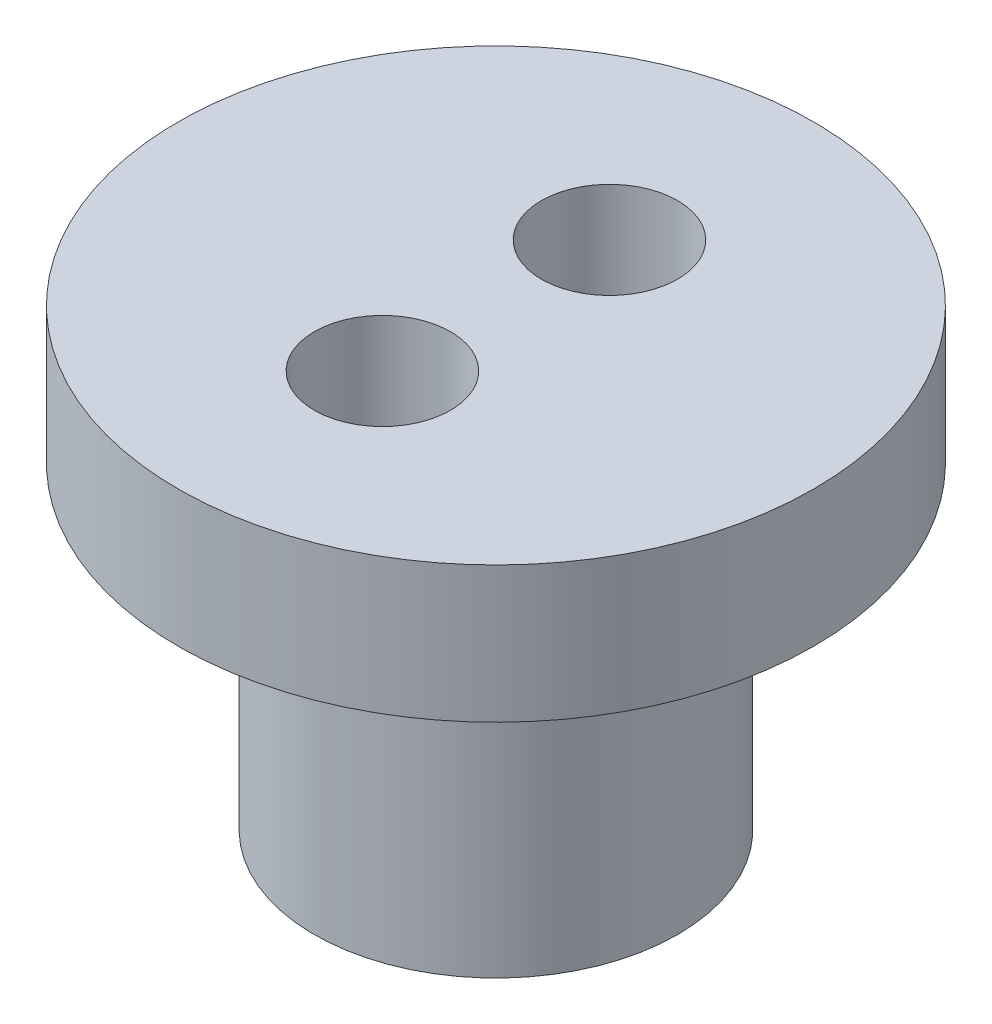
from build123d import *

# Parameters (mm, degrees)
FILLET1_R          = 1
SKETCH2_R          = 1.5
CUT_EXTRUDE1_DEPTH = 3


with BuildPart() as part:
    # Sketch1 → Revolve1 (revolve)
    with BuildSketch(Plane.XY):
        Polygon((2, 0), (2, 4), (0, 4), (0, 10), (7, 10), (7, 7), (4, 7), (4, 0), align=None)
    revolve(axis=Axis((0, 4, 0), (0, 1, 0)))

    # Fillet1
    fillet1_edges = [part.edges().sort_by_distance(p)[0] for p in [
        (-4, 7, 0),
    ]]
    fillet(fillet1_edges, radius=FILLET1_R)

    # Sketch2 → Cut-Extrude1 (cut)
    with BuildSketch(Plane(origin=(0, 10, 0), x_dir=(1, 0, 0), z_dir=(0, 1, 0))):
        with Locations((0, 2.5)):
            Circle(SKETCH2_R)
        with Locations((0, -2.5)):
            Circle(SKETCH2_R)
    extrude(amount=-CUT_EXTRUDE1_DEPTH, mode=Mode.SUBTRACT)


solid = part.part
